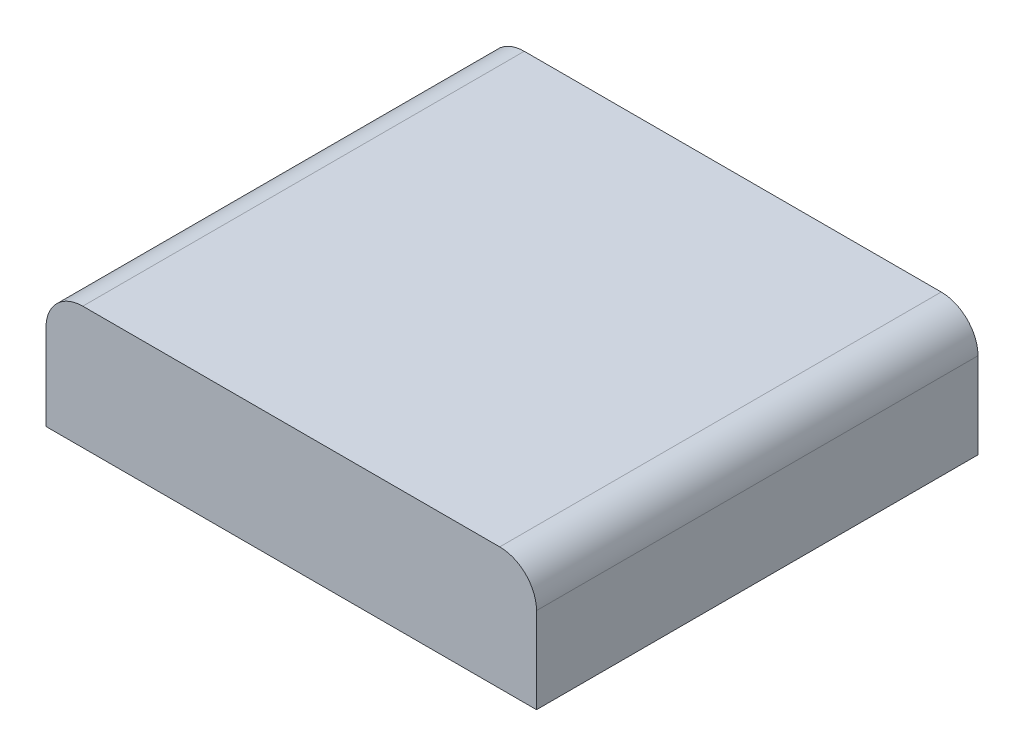
from build123d import *

# Parameters (mm, degrees)
BOSS_EXTRUDE1_DEPTH = 57.15


with BuildPart() as part:
    # Sketch1 → Boss-Extrude1 (new body)
    with BuildSketch(Plane.XY):
        with BuildLine():
            Line((0, 0), (63.5, 0))
            Line((63.5, 0), (63.5, 11.1125))
            ThreePointArc((63.5, 11.1125), (62.105096045, 14.480096045), (58.7375, 15.875))
            Line((58.7375, 15.875), (4.7625, 15.875))
            ThreePointArc((4.7625, 15.875), (1.394903955, 14.480096045), (0, 11.1125))
            Line((0, 11.1125), (0, 0))
        make_face()
    extrude(amount=BOSS_EXTRUDE1_DEPTH)


solid = part.part
